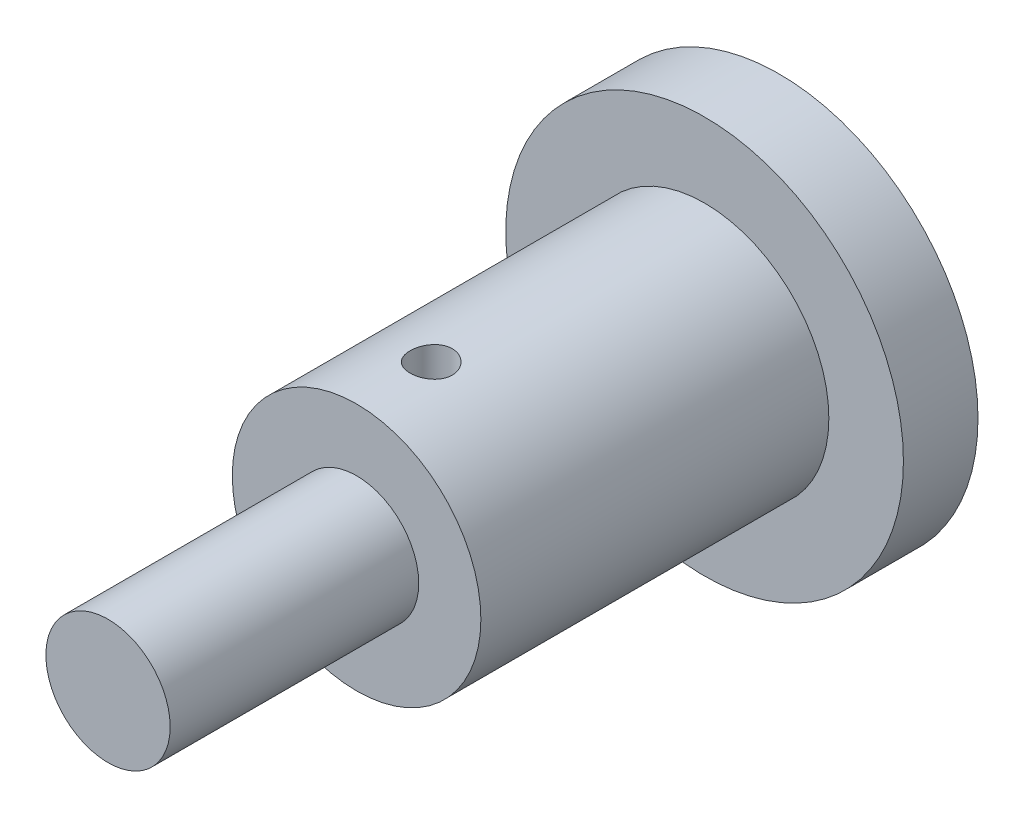
from build123d import *

# Parameters (mm, degrees)
SKETCH1_R           = 8
BOSS_EXTRUDE1_DEPTH = 3
SKETCH2_R           = 5
BOSS_EXTRUDE2_DEPTH = 14
SKETCH3_R           = 2.5
BOSS_EXTRUDE3_DEPTH = 10
SKETCH4_R           = 0.85
CUT_EXTRUDE1_DEPTH  = 7.5


with BuildPart() as part:
    # Sketch1 → Boss-Extrude1 (new body)
    with BuildSketch(Plane.XY):
        Circle(SKETCH1_R)
    extrude(amount=BOSS_EXTRUDE1_DEPTH)

    # Sketch2 → Boss-Extrude2 (add)
    with BuildSketch(Plane.XY.offset(3)):
        Circle(SKETCH2_R)
    extrude(amount=BOSS_EXTRUDE2_DEPTH)

    # Sketch3 → Boss-Extrude3 (add)
    with BuildSketch(Plane.XY.offset(17)):
        Circle(SKETCH3_R)
    extrude(amount=BOSS_EXTRUDE3_DEPTH)

    # Sketch4 → Cut-Extrude1 (cut, symmetric)
    with BuildSketch(Plane(origin=(0, 0, 0), x_dir=(1, 0, 0), z_dir=(0, 1, 0))):
        with Locations((0, -14)):
            Circle(SKETCH4_R)
    extrude(amount=CUT_EXTRUDE1_DEPTH, both=True, mode=Mode.SUBTRACT)


solid = part.part
